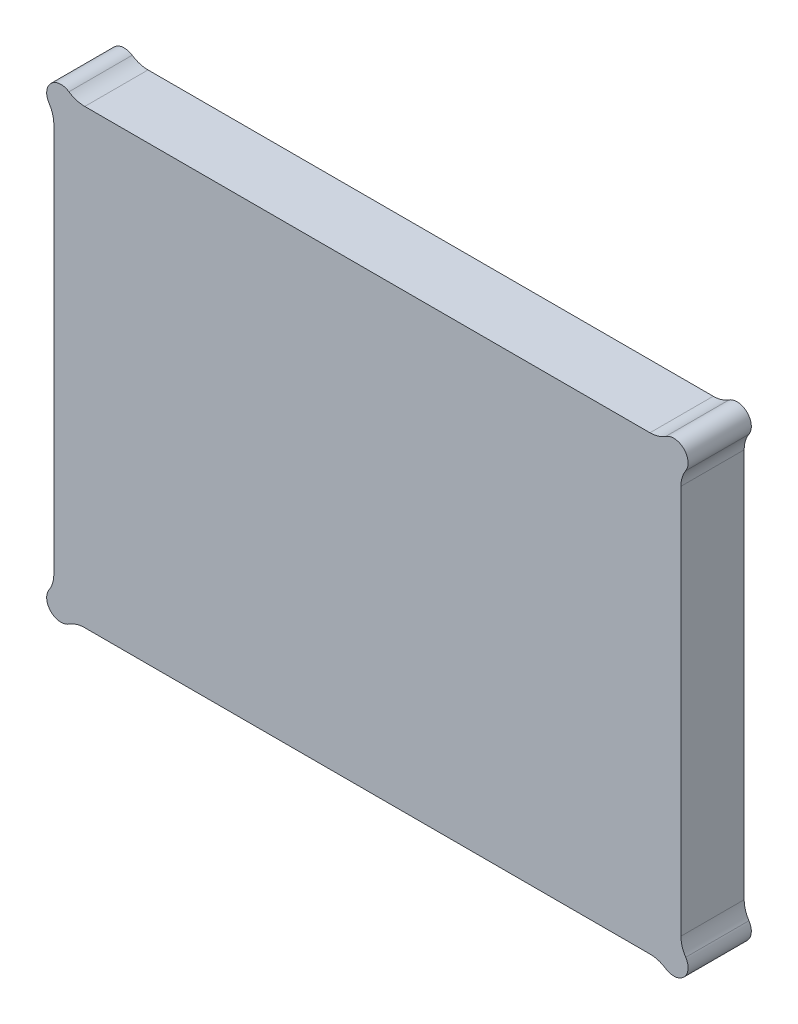
from build123d import *

# Parameters (mm, degrees)
BOSS_EXTRUDE1_START     = 2
SKETCH1_W               = 175
SKETCH1_H               = 126
BOSS_EXTRUDE1_DEPTH     = 2
SKETCH2_R               = 5
BOSS_EXTRUDE2_DEPTH     = 2
FILLET1_R               = 2
BOSS_EXTRUDE3_DEPTH     = 15.65
CUT_EXTRUDE_THIN1_DEPTH = 2.25
SKETCH8_R               = 4
BOSS_EXTRUDE4_DEPTH     = 17.65
FILLET2_R               = 8


with BuildPart() as part:
    # Sketch1 → Boss-Extrude1 (new body)
    with BuildSketch(Plane.XY.offset(BOSS_EXTRUDE1_START)):
        with Locations((-70.5, 46)):
            Rectangle(SKETCH1_W, SKETCH1_H)
    extrude(amount=BOSS_EXTRUDE1_DEPTH)

    # Sketch2 → Boss-Extrude2 (add)
    with BuildSketch(Plane(origin=(0, 0, 2), x_dir=(-1, 0, 0), z_dir=(0, 0, -1))):
        Circle(SKETCH2_R)
        with Locations((69.5, 63.5)):
            Circle(SKETCH2_R)
        with Locations((0, 92)):
            Circle(SKETCH2_R)
        with Locations((141, 92)):
            Circle(SKETCH2_R)
        with Locations((141, 0)):
            Circle(SKETCH2_R)
    extrude(amount=BOSS_EXTRUDE2_DEPTH)

    # Fillet1
    fillet1_edges = [part.edges().sort_by_distance(p)[0] for p in [
        (-158, 109, 3),
        (17, 109, 3),
        (17, -17, 3),
        (-158, -17, 3),
    ]]
    fillet(fillet1_edges, radius=FILLET1_R)

    # Sketch3 → Boss-Extrude3 (add)
    with BuildSketch(Plane(origin=(0, 0, 2), x_dir=(-1, 0, 0), z_dir=(0, 0, -1))):
        with BuildLine():
            Line((-15, 109), (156, 109))
            ThreePointArc((156, 109), (157.414213562, 108.414213562), (158, 107))
            Line((158, 107), (158, -15))
            ThreePointArc((158, -15), (157.414213562, -16.414213562), (156, -17))
            Line((156, -17), (-15, -17))
            ThreePointArc((-15, -17), (-16.414213562, -16.414213562), (-17, -15))
            Line((-17, -15), (-17, 107))
            ThreePointArc((-17, 107), (-16.414213562, 108.414213562), (-15, 109))
        make_face()
        with BuildLine():
            Line((-3, 102), (144, 102))
            ThreePointArc((144, 102), (148.949747468, 99.949747468), (151, 95))
            Line((151, 95), (151, -3))
            ThreePointArc((151, -3), (148.949747468, -7.949747468), (144, -10))
            Line((144, -10), (-3, -10))
            ThreePointArc((-3, -10), (-7.949747468, -7.949747468), (-10, -3))
            Line((-10, -3), (-10, 95))
            ThreePointArc((-10, 95), (-7.949747468, 99.949747468), (-3, 102))
        make_face(mode=Mode.SUBTRACT)
    extrude(amount=BOSS_EXTRUDE3_DEPTH)

    # Sketch5 → Cut-Extrude-Thin1 (cut)
    with BuildSketch(Plane(origin=(0, 0, -13.65), x_dir=(-1, 0, 0), z_dir=(0, 0, -1))):
        with BuildLine():
            Line((-3, 107), (144, 107))
            ThreePointArc((144, 107), (152.485281374, 103.485281374), (156, 95))
            Line((156, 95), (156, -3))
            ThreePointArc((156, -3), (152.485281374, -11.485281374), (144, -15))
            Line((144, -15), (-3, -15))
            ThreePointArc((-3, -15), (-11.485281374, -11.485281374), (-15, -3))
            Line((-15, -3), (-15, 95))
            ThreePointArc((-15, 95), (-11.485281374, 103.485281374), (-3, 107))
        make_face()
        with BuildLine():
            Line((-3, 104), (144, 104))
            ThreePointArc((144, 104), (150.363961031, 101.363961031), (153, 95))
            Line((153, 95), (153, -3))
            ThreePointArc((153, -3), (150.363961031, -9.363961031), (144, -12))
            Line((144, -12), (-3, -12))
            ThreePointArc((-3, -12), (-9.363961031, -9.363961031), (-12, -3))
            Line((-12, -3), (-12, 95))
            ThreePointArc((-12, 95), (-9.363961031, 101.363961031), (-3, 104))
        make_face(mode=Mode.SUBTRACT)
    extrude(amount=-CUT_EXTRUDE_THIN1_DEPTH, mode=Mode.SUBTRACT)

    # Sketch8 → Boss-Extrude4 (add)
    with BuildSketch(Plane(origin=(0, 0, -13.65), x_dir=(-1, 0, 0), z_dir=(0, 0, -1))):
        with Locations((156, 107)):
            Circle(SKETCH8_R)
        with Locations((156, -15)):
            Circle(SKETCH8_R)
        with Locations((-15, -15)):
            Circle(SKETCH8_R)
        with Locations((-15, 107)):
            Circle(SKETCH8_R)
    extrude(amount=-BOSS_EXTRUDE4_DEPTH)

    # Fillet2
    fillet2_edges = [part.edges().sort_by_distance(p)[0] for p in [
        (-152.535898385, 109, -4.825),
        (-158, 103.535898385, -4.825),
        (-158, -11.535898385, -4.825),
        (-152.535898385, -17, -4.825),
        (11.535898385, -17, -4.825),
        (17, -11.535898385, -4.825),
        (11.535898385, 109, -4.825),
        (17, 103.535898385, -4.825),
    ]]
    fillet(fillet2_edges, radius=FILLET2_R)


solid = part.part
